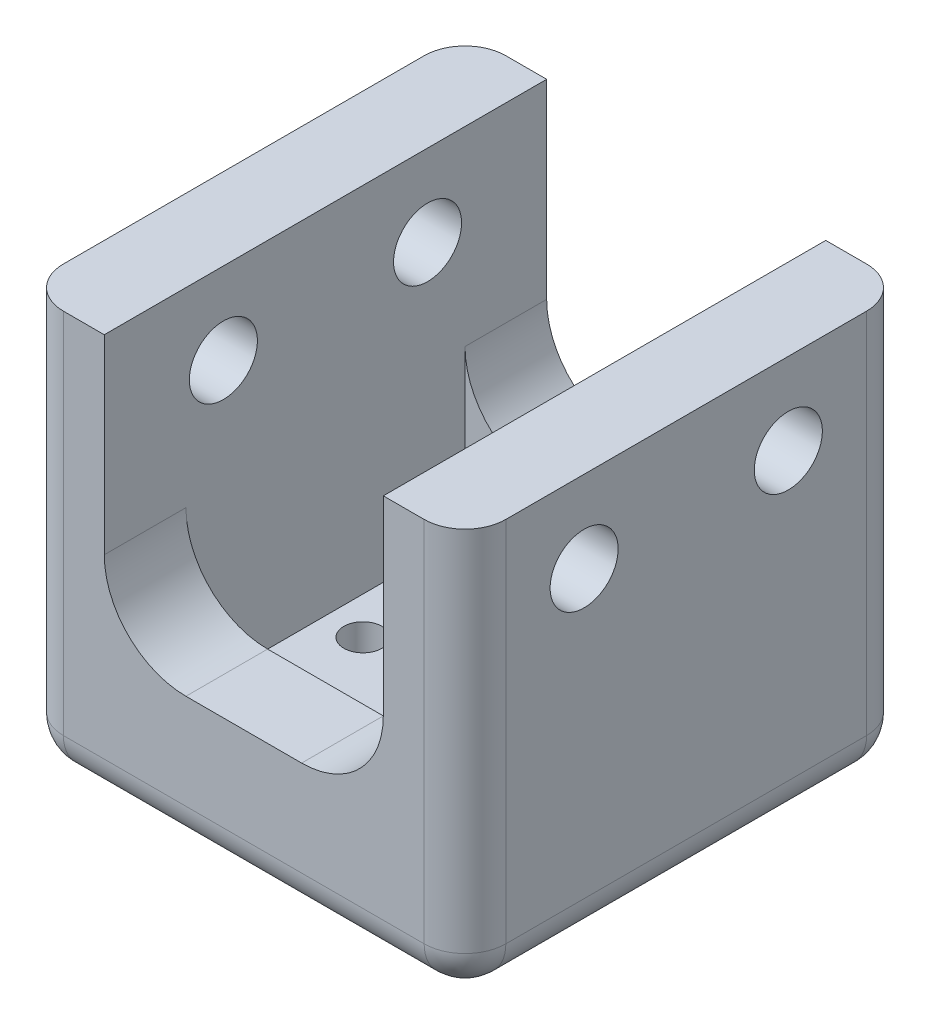
from build123d import *

# Parameters (mm, degrees)
SKETCH1_W           = 26.035
SKETCH1_H           = 26.035
SKETCH1_R           = 1.778
BOSS_EXTRUDE1_DEPTH = 5.08
SKETCH9_W           = 41.275
SKETCH9_H           = 41.275
SKETCH9_W_2         = 26.035
SKETCH9_H_2         = 26.035
BOSS_EXTRUDE7_DEPTH = 38.1
CUT_EXTRUDE4_DEPTH  = 42.275
SKETCH11_R          = 3.175
CUT_EXTRUDE5_DEPTH  = 42.275
FILLET1_R           = 3.81
FILLET2_R           = 3.81


with BuildPart() as part:
    # Sketch1 → Boss-Extrude1 (new body)
    with BuildSketch(Plane(origin=(0, 0, 0), x_dir=(1, 0, 0), z_dir=(0, 1, 0))):
        Rectangle(SKETCH1_W, SKETCH1_H)
        with Locations((0, 9.525)):
            Circle(SKETCH1_R, mode=Mode.SUBTRACT)
        with Locations((-9.525, 0)):
            Circle(SKETCH1_R, mode=Mode.SUBTRACT)
        with Locations((9.525, 0)):
            Circle(SKETCH1_R, mode=Mode.SUBTRACT)
        with Locations((0, -9.525)):
            Circle(SKETCH1_R, mode=Mode.SUBTRACT)
    extrude(amount=BOSS_EXTRUDE1_DEPTH)

    # Sketch9 → Boss-Extrude7 (add)
    with BuildSketch(Plane.XZ):
        Rectangle(SKETCH9_W, SKETCH9_H)
        Rectangle(SKETCH9_W_2, SKETCH9_H_2, mode=Mode.SUBTRACT)
    extrude(amount=-BOSS_EXTRUDE7_DEPTH)

    # Sketch10 → Cut-Extrude4 (cut, through all)
    with BuildSketch(Plane.XY.offset(20.6375)):
        with BuildLine():
            Line((-13.0175, 20.32), (-13.0175, 38.1))
            Line((-13.0175, 38.1), (13.0175, 38.1))
            Line((13.0175, 38.1), (13.0175, 20.32))
            ThreePointArc((13.0175, 20.32), (10.785653673, 14.931846327), (5.3975, 12.7))
            Line((5.3975, 12.7), (-5.3975, 12.7))
            ThreePointArc((-5.3975, 12.7), (-10.785653673, 14.931846327), (-13.0175, 20.32))
        make_face()
    extrude(amount=-CUT_EXTRUDE4_DEPTH, mode=Mode.SUBTRACT)

    # Sketch11 → Cut-Extrude5 (cut, through all)
    with BuildSketch(Plane.ZY.offset(20.6375)):
        with Locations((-9.525, 30.48)):
            Circle(SKETCH11_R)
        with Locations((9.525, 30.48)):
            Circle(SKETCH11_R)
    extrude(amount=-CUT_EXTRUDE5_DEPTH, mode=Mode.SUBTRACT)

    # Fillet1
    fillet1_edges = [part.edges().sort_by_distance(p)[0] for p in [
        (20.6375, 19.05, -20.6375),
        (-20.6375, 19.05, -20.6375),
        (-20.6375, 19.05, 20.6375),
        (20.6375, 19.05, 20.6375),
    ]]
    fillet(fillet1_edges, radius=FILLET1_R)

    # Fillet2
    fillet2_edges = [part.edges().sort_by_distance(p)[0] for p in [
        (0, 0, -20.6375),
        (20.6375, 0, 0),
        (0, 0, 20.6375),
        (-20.6375, 0, 0),
        (-19.521576836, 0, 19.521576836),
        (-19.521576836, 0, -19.521576836),
        (19.521576836, 0, 19.521576836),
        (19.521576836, 0, -19.521576836),
    ]]
    fillet(fillet2_edges, radius=FILLET2_R)


solid = part.part
